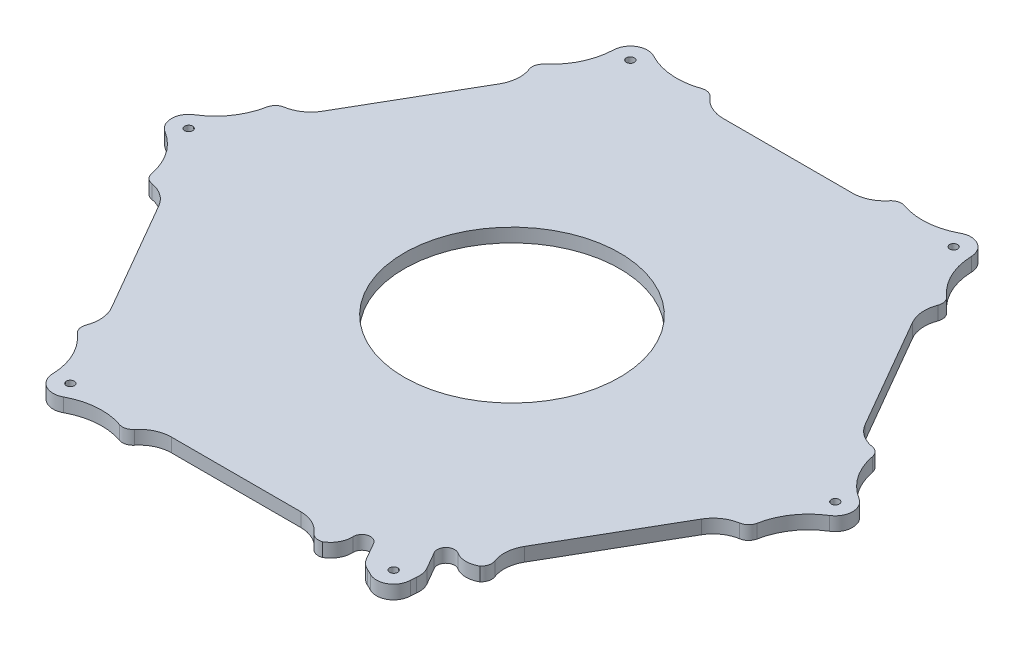
from build123d import *

# Parameters (mm, degrees)
SKETCH1_R           = 1.85
SKETCH1_R_2         = 50
BOSS_EXTRUDE1_DEPTH = 6.35


with BuildPart() as part:
    # Sketch1 → Boss-Extrude1 (new body)
    with BuildSketch(Plane(origin=(0, 0, 0), x_dir=(1, 0, 0), z_dir=(0, 1, 0))):
        with BuildLine():
            Line((77.567379868, -113.774878941), (81.895896581, -121.29702529))
            Line((81.895896581, -121.29702529), (81.904324829, -121.31160095))
            ThreePointArc((81.904324829, -121.31160095), (83.049348254, -124.303633996), (83.189448927, -127.504213973))
            ThreePointArc((83.189448927, -127.504213973), (83.064062558, -128.818339264), (82.996609195, -130.136708357))
            ThreePointArc((82.996609195, -130.136708357), (79, -136.832013798), (71.203390805, -136.94552617))
            ThreePointArc((71.203390805, -136.94552617), (70.027922997, -136.344757949), (68.827163927, -135.796283084))
            ThreePointArc((68.827163927, -135.796283084), (66.125430696, -134.074662353), (64.106765781, -131.587026457))
            Line((64.106765781, -131.587026457), (64.101233791, -131.577414018))
            Line((64.101233791, -131.577414018), (59.601233791, -123.783185384))
            ThreePointArc((59.601233791, -123.783185384), (55.026304797, -121.940521916), (52.14020721, -125.939999968))
            ThreePointArc((52.14020721, -125.939999968), (50.889960833, -131.187577731), (47.09575677, -135.022183828))
            ThreePointArc((47.09575677, -135.022183828), (44.098818948, -135.114328678), (41.588023883, -133.475415889))
            ThreePointArc((41.588023883, -133.475415889), (36.408246185, -129.437759004), (30, -128))
            Line((30, -128), (-30, -128))
            ThreePointArc((-30, -128), (-36.408246185, -129.437759004), (-41.588023883, -133.475415889))
            ThreePointArc((-41.588023883, -133.475415889), (-44.098818948, -135.114328677), (-47.09575677, -135.022183828))
            ThreePointArc((-47.09575677, -135.022183828), (-59.351969188, -133.446982526), (-71.203390805, -136.94552617))
            ThreePointArc((-71.203390805, -136.94552617), (-79, -136.832013798), (-82.996609195, -130.136708357))
            ThreePointArc((-82.996609195, -130.136708357), (-85.892492332, -118.123804344), (-93.384762884, -108.297213687))
            ThreePointArc((-93.384762884, -108.297213687), (-94.963031576, -105.747861824), (-94.799088999, -102.753993121))
            ThreePointArc((-94.799088999, -102.753993121), (-93.892264414, -96.249345606), (-95.851251684, -89.980762113))
            Line((-95.851251684, -89.980762113), (-125.851251684, -38.019237886))
            ThreePointArc((-125.851251684, -38.019237886), (-130.300510599, -33.188413398), (-136.387112883, -30.721422769))
            ThreePointArc((-136.387112883, -30.721422769), (-139.061850524, -29.366466853), (-140.480519654, -26.724970141))
            ThreePointArc((-140.480519654, -26.724970141), (-145.24446152, -15.323178182), (-154.2, -6.808817812))
            ThreePointArc((-154.2, -6.808817812), (-158, 0), (-154.2, 6.808817812))
            ThreePointArc((-154.2, 6.808817812), (-145.24446152, 15.323178182), (-140.480519654, 26.72497014))
            ThreePointArc((-140.480519654, 26.72497014), (-139.061850524, 29.366466853), (-136.387112883, 30.721422769))
            ThreePointArc((-136.387112883, 30.721422769), (-130.300510599, 33.188413398), (-125.851251684, 38.019237887))
            Line((-125.851251684, 38.019237887), (-95.851251684, 89.980762114))
            ThreePointArc((-95.851251684, 89.980762114), (-93.892264414, 96.249345606), (-94.799088999, 102.753993121))
            ThreePointArc((-94.799088999, 102.753993121), (-94.963031576, 105.747861824), (-93.384762884, 108.297213687))
            ThreePointArc((-93.384762884, 108.297213687), (-85.892492332, 118.123804344), (-82.996609195, 130.136708357))
            ThreePointArc((-82.996609195, 130.136708357), (-79, 136.832013798), (-71.203390805, 136.94552617))
            ThreePointArc((-71.203390805, 136.94552617), (-59.351969188, 133.446982526), (-47.09575677, 135.022183827))
            ThreePointArc((-47.09575677, 135.022183827), (-44.098818948, 135.114328677), (-41.588023883, 133.475415889))
            ThreePointArc((-41.588023883, 133.475415889), (-36.408246185, 129.437759004), (-30, 128))
            Line((-30, 128), (30, 128))
            ThreePointArc((30, 128), (36.408246185, 129.437759004), (41.588023883, 133.475415889))
            ThreePointArc((41.588023883, 133.475415889), (44.098818948, 135.114328677), (47.09575677, 135.022183827))
            ThreePointArc((47.09575677, 135.022183827), (59.351969188, 133.446982526), (71.203390805, 136.94552617))
            ThreePointArc((71.203390805, 136.94552617), (79, 136.832013798), (82.996609195, 130.136708357))
            ThreePointArc((82.996609195, 130.136708357), (85.892492332, 118.123804344), (93.384762884, 108.297213687))
            ThreePointArc((93.384762884, 108.297213687), (94.963031576, 105.747861824), (94.799088999, 102.753993121))
            ThreePointArc((94.799088999, 102.753993121), (93.892264414, 96.249345606), (95.851251684, 89.980762113))
            Line((95.851251684, 89.980762113), (125.851251684, 38.019237886))
            ThreePointArc((125.851251684, 38.019237886), (130.300510599, 33.188413398), (136.387112882, 30.721422769))
            ThreePointArc((136.387112882, 30.721422769), (139.061850524, 29.366466853), (140.480519654, 26.72497014))
            ThreePointArc((140.480519654, 26.72497014), (145.24446152, 15.323178182), (154.2, 6.808817812))
            ThreePointArc((154.2, 6.808817812), (158, 0), (154.2, -6.808817812))
            ThreePointArc((154.2, -6.808817812), (145.24446152, -15.323178182), (140.480519654, -26.72497014))
            ThreePointArc((140.480519654, -26.72497014), (139.061850524, -29.366466853), (136.387112882, -30.721422769))
            ThreePointArc((136.387112882, -30.721422769), (130.300510599, -33.188413399), (125.851251684, -38.019237887))
            Line((125.851251684, -38.019237887), (95.851251684, -89.980762114))
            ThreePointArc((95.851251684, -89.980762114), (93.892264414, -96.249345606), (94.799088999, -102.753993121))
            ThreePointArc((94.799088999, -102.753993121), (94.963031576, -105.747861824), (93.384762884, -108.297213687))
            ThreePointArc((93.384762884, -108.297213687), (88.166794559, -109.665787745), (82.997135719, -108.124743986))
            ThreePointArc((82.997135719, -108.124743986), (77.978753703, -108.736153752), (77.567379868, -113.774878941))
        make_face()
        with Locations((-75, -129.903810568)):
            Circle(SKETCH1_R, mode=Mode.SUBTRACT)
        with Locations((75, -129.903810568)):
            Circle(SKETCH1_R, mode=Mode.SUBTRACT)
        with Locations((150, 0)):
            Circle(SKETCH1_R, mode=Mode.SUBTRACT)
        with Locations((75, 129.903810568)):
            Circle(SKETCH1_R, mode=Mode.SUBTRACT)
        with Locations((-75, 129.903810568)):
            Circle(SKETCH1_R, mode=Mode.SUBTRACT)
        with Locations((-150, 0)):
            Circle(SKETCH1_R, mode=Mode.SUBTRACT)
        Circle(SKETCH1_R_2, mode=Mode.SUBTRACT)
    extrude(amount=BOSS_EXTRUDE1_DEPTH)


solid = part.part
